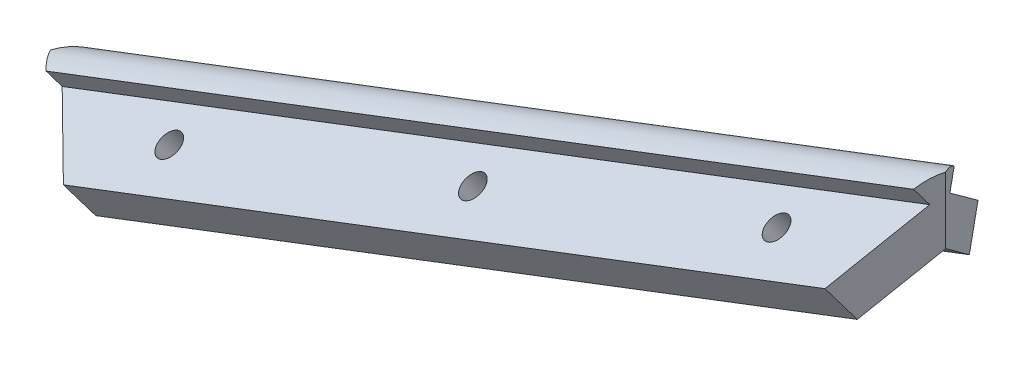
from build123d import *

# Parameters (mm, degrees)
BOSS_EXTRUDE1_DEPTH = 76.2
CUT_EXTRUDE2_START  = -64.90373811
CUT_EXTRUDE2_DEPTH  = 68.722745412
SKETCH4_R           = 1.7145
CUT_EXTRUDE3_DEPTH  = 2.5
SKETCH6_R           = 1.7145
CUT_EXTRUDE4_DEPTH  = 50.868554483


with BuildPart() as part:
    # Sketch2 → Boss-Extrude1 (new body, symmetric)
    with BuildSketch(Plane(origin=(-61.535605536, -23.504509797, 0), x_dir=(0, 0, 1), z_dir=(-0.934172359, -0.35682209, 0))):
        with BuildLine():
            Line((-1.374815328, -3.984929137), (-2.776940204, -1.716243431))
            ThreePointArc((-2.776940204, -1.716243431), (-1.443408604, -1.128416568), (0, -0.927372913))
            Line((0, -0.927372913), (0, -9.404564037))
            Line((0, -9.404564037), (-7.662421822, -14.140201159))
            Line((-7.662421822, -14.140201159), (-10.466145843, -9.603680398))
            Line((-10.466145843, -9.603680398), (-1.374815328, -3.984929137))
        make_face()
    boss_extrude1 = extrude(amount=BOSS_EXTRUDE1_DEPTH, both=True)

    # Mirror4: Boss-Extrude1 across plane
    add(boss_extrude1.mirror(Plane(origin=(13.00408441, -5.100150327, 0), x_dir=(1, 0, 0), z_dir=(0, 0, 1))))

    # Sketch3 → Cut-Extrude2 (cut)
    with BuildSketch(Plane(origin=(0, 0, 0), x_dir=(1, 0, 0), z_dir=(0, 1, 0)).offset(CUT_EXTRUDE2_START)):
        Polygon((-6.04263212, 10.466145843), (0, 0), (-6.04263212, -10.466145843), (57.45736788, -10.466145843), (57.45736788, 10.466145843), align=None)
    cut_extrude2 = extrude(amount=CUT_EXTRUDE2_DEPTH, mode=Mode.SUBTRACT)

    # Mirror5: Cut-Extrude2 across plane
    add(cut_extrude2.mirror(Plane(origin=(-61.535605536, -23.504509797, 0), x_dir=(0, 0, 1), z_dir=(0.934172359, 0.35682209, 0))), mode=Mode.SUBTRACT)

    # Sketch4 → Cut-Extrude3 (cut)
    with BuildSketch(Plane(origin=(2.428247993, -6.357235778, 4.205848897), x_dir=(0.952821564, 0.253145264, -0.167476992), z_dir=(0.303530999, -0.794654472, 0.525731112))):
        Polygon((-109.695418088, -30.215326769), (-107.597357756, -32.598911501), (-104.48408266, -31.973730321), (-103.468867896, -28.964964409), (-105.566928228, -26.581379677), (-108.680203324, -27.206560857), align=None)
        with Locations((-106.582142992, -29.590145589)):
            Circle(SKETCH4_R, mode=Mode.SUBTRACT)
        Polygon((-66.115420605, -21.46396577), (-64.017360273, -23.847550502), (-60.904085176, -23.222369322), (-59.888870412, -20.21360341), (-61.986930744, -17.830018678), (-65.100205841, -18.455199858), align=None)
        with Locations((-63.002145509, -20.83878459)):
            Circle(SKETCH4_R, mode=Mode.SUBTRACT)
        Polygon((-22.535423121, -12.712604771), (-20.437362789, -15.096189503), (-17.324087693, -14.471008323), (-16.308872929, -11.462242411), (-18.406933261, -9.078657679), (-21.520208357, -9.703838859), align=None)
        with Locations((-19.422148025, -12.087423591)):
            Circle(SKETCH4_R, mode=Mode.SUBTRACT)
    cut_extrude3 = extrude(amount=-CUT_EXTRUDE3_DEPTH, mode=Mode.SUBTRACT)

    # Sketch6 → Cut-Extrude4 (cut, through all)
    with BuildSketch(Plane(origin=(2.428247993, -6.357235778, 4.205848897), x_dir=(0.952821564, 0.253145264, -0.167476992), z_dir=(0.303530999, -0.794654472, 0.525731112))):
        with Locations((-106.582142992, -29.590145589)):
            Circle(SKETCH6_R)
        with Locations((-63.002145509, -20.83878459)):
            Circle(SKETCH6_R)
        with Locations((-19.422148025, -12.087423591)):
            Circle(SKETCH6_R)
    cut_extrude4 = extrude(amount=-CUT_EXTRUDE4_DEPTH, mode=Mode.SUBTRACT)

    # Mirror6: Cut-Extrude3, Cut-Extrude4 across plane
    add(cut_extrude3.mirror(Plane.XY), mode=Mode.SUBTRACT)
    add(cut_extrude4.mirror(Plane.XY), mode=Mode.SUBTRACT)


solid = part.part
